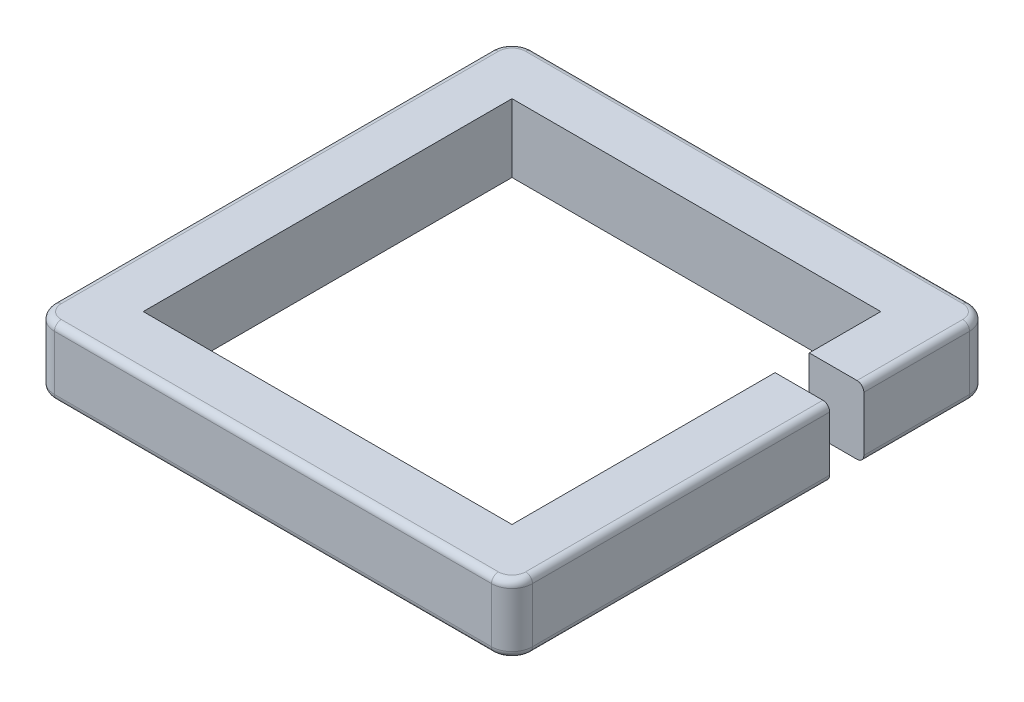
from build123d import *

# Parameters (mm, degrees)
SKETCH1_W           = 889
SKETCH1_H           = 889
SKETCH1_W_2         = 685.8
SKETCH1_H_2         = 685.8
BOSS_EXTRUDE1_DEPTH = 127
FILLET1_R           = 38.1
FILLET2_R           = 12.7
SKETCH2_W           = 101.6
SKETCH2_H           = 63.5
CUT_EXTRUDE1_DEPTH  = 128


with BuildPart() as part:
    # Sketch1 → Boss-Extrude1 (new body)
    with BuildSketch(Plane(origin=(0, 0, 0), x_dir=(1, 0, 0), z_dir=(0, 1, 0))):
        Rectangle(SKETCH1_W, SKETCH1_H)
        Rectangle(SKETCH1_W_2, SKETCH1_H_2, mode=Mode.SUBTRACT)
    extrude(amount=BOSS_EXTRUDE1_DEPTH)

    # Fillet1
    fillet1_edges = [part.edges().sort_by_distance(p)[0] for p in [
        (444.5, 63.5, -444.5),
        (444.5, 63.5, 444.5),
        (-444.5, 63.5, 444.5),
        (-444.5, 63.5, -444.5),
    ]]
    fillet(fillet1_edges, radius=FILLET1_R)

    # Fillet2
    fillet2_edges = [part.edges().sort_by_distance(p)[0] for p in [
        (-444.5, 0, 0),
        (-444.5, 127, 0),
        (0, 0, -444.5),
        (444.5, 0, 0),
        (0, 0, 444.5),
        (-433.340768363, 0, 433.340768363),
        (433.340768363, 0, 433.340768363),
        (433.340768363, 0, -433.340768363),
        (-433.340768363, 0, -433.340768363),
        (0, 127, -444.5),
        (0, 127, 444.5),
        (444.5, 127, 0),
        (-433.340768363, 127, 433.340768363),
        (433.340768363, 127, 433.340768363),
        (433.340768363, 127, -433.340768363),
        (-433.340768363, 127, -433.340768363),
    ]]
    fillet(fillet2_edges, radius=FILLET2_R)

    # Sketch2 → Cut-Extrude1 (cut, through all)
    with BuildSketch(Plane(origin=(0, 127, 0), x_dir=(1, 0, 0), z_dir=(0, 1, 0))):
        with Locations((393.7, 178.054)):
            Rectangle(SKETCH2_W, SKETCH2_H)
    extrude(amount=-CUT_EXTRUDE1_DEPTH, mode=Mode.SUBTRACT)


solid = part.part
